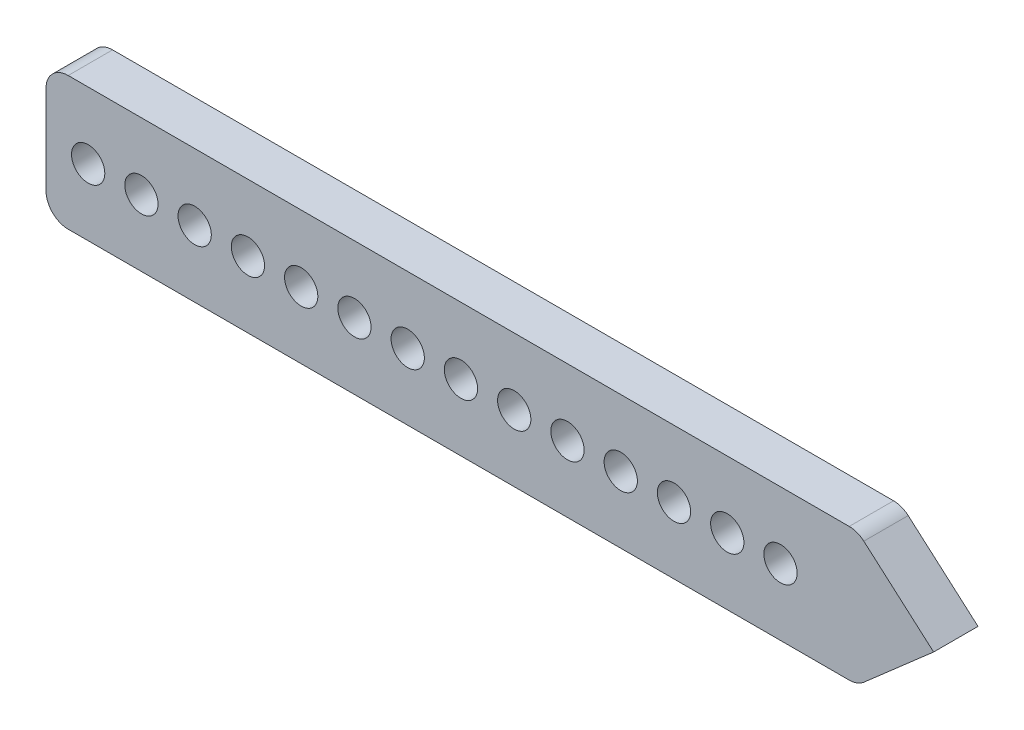
from build123d import *

# Parameters (mm, degrees)
CROQUIS2_R              = 0.75
SALIENTE_EXTRUIR1_DEPTH = 2


with BuildPart() as part:
    # Croquis2 → Saliente-Extruir1 (new body)
    with BuildSketch(Plane.XY):
        with BuildLine():
            Line((18.568483774, -2.752576707), (21.714285714, -1.14e-07))
            Line((21.714285714, -1.14e-07), (18.568483781, 2.752576682))
            ThreePointArc((18.568483781, 2.752576682), (18.261705841, 2.936102741), (17.909979159, 3))
            Line((17.909979159, 3), (-17.285714286, 3))
            ThreePointArc((-17.285714286, 3), (-17.992821067, 2.707106781), (-18.285714286, 2))
            Line((-18.285714286, 2), (-18.285714286, -2))
            ThreePointArc((-18.285714286, -2), (-17.992821067, -2.707106781), (-17.285714286, -3))
            Line((-17.285714286, -3), (17.90997918, -3))
            ThreePointArc((17.90997918, -3), (18.261705845, -2.936102747), (18.568483774, -2.752576707))
        make_face()
        with Locations((-16.385714286, 0)):
            Circle(CROQUIS2_R, mode=Mode.SUBTRACT)
        with Locations((-13.985714286, 0)):
            Circle(CROQUIS2_R, mode=Mode.SUBTRACT)
        with Locations((-11.585714286, 0)):
            Circle(CROQUIS2_R, mode=Mode.SUBTRACT)
        with Locations((-9.185714286, 0)):
            Circle(CROQUIS2_R, mode=Mode.SUBTRACT)
        with Locations((-6.785714286, 0)):
            Circle(CROQUIS2_R, mode=Mode.SUBTRACT)
        with Locations((-4.385714286, 0)):
            Circle(CROQUIS2_R, mode=Mode.SUBTRACT)
        with Locations((-1.985714286, 0)):
            Circle(CROQUIS2_R, mode=Mode.SUBTRACT)
        with Locations((0.414285714, 0)):
            Circle(CROQUIS2_R, mode=Mode.SUBTRACT)
        with Locations((2.814285714, 0)):
            Circle(CROQUIS2_R, mode=Mode.SUBTRACT)
        with Locations((5.214285714, 0)):
            Circle(CROQUIS2_R, mode=Mode.SUBTRACT)
        with Locations((7.614285714, 0)):
            Circle(CROQUIS2_R, mode=Mode.SUBTRACT)
        with Locations((10.014285714, 0)):
            Circle(CROQUIS2_R, mode=Mode.SUBTRACT)
        with Locations((12.414285714, 0)):
            Circle(CROQUIS2_R, mode=Mode.SUBTRACT)
        with Locations((14.814285714, 0)):
            Circle(CROQUIS2_R, mode=Mode.SUBTRACT)
    extrude(amount=SALIENTE_EXTRUIR1_DEPTH)


solid = part.part
